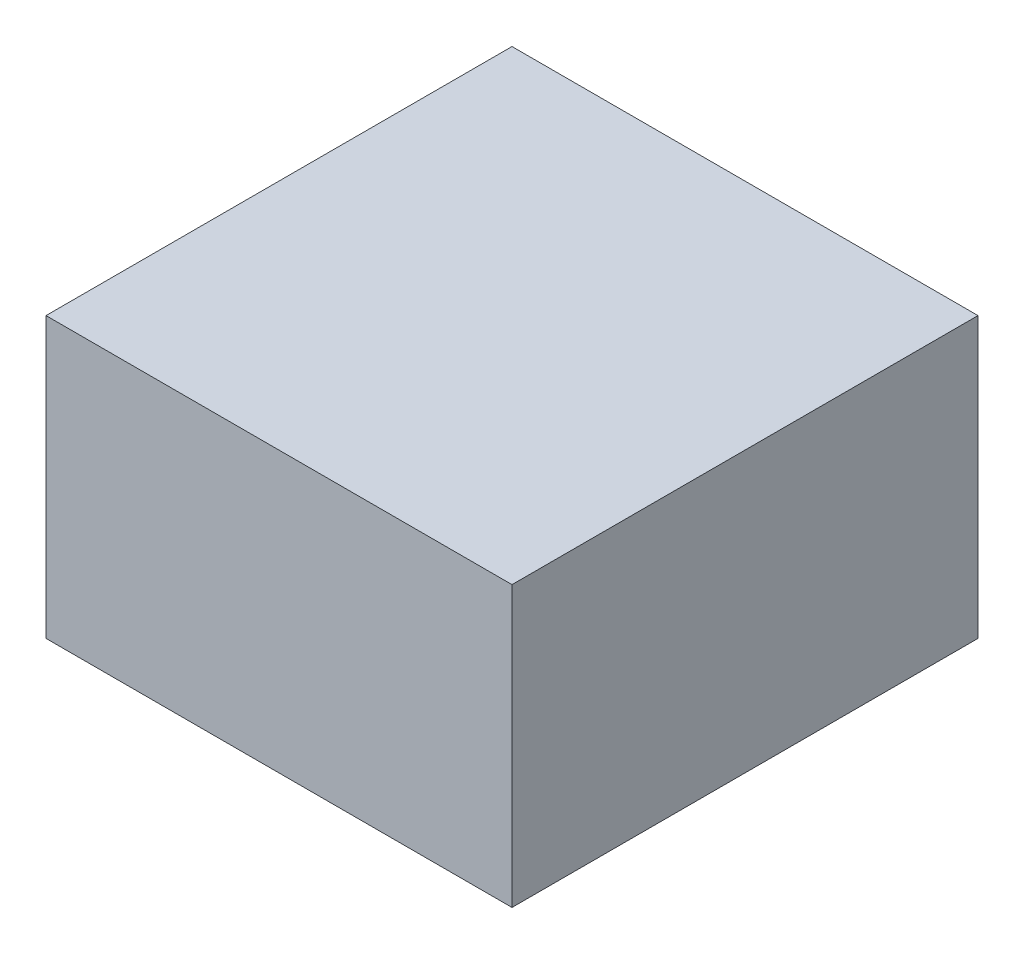
from build123d import *

# Parameters (mm, degrees)
SKETCH1_W           = 63.5
SKETCH1_H           = 63.5
BOSS_EXTRUDE1_DEPTH = 38.1


with BuildPart() as part:
    # Sketch1 → Boss-Extrude1 (new body)
    with BuildSketch(Plane(origin=(0, 0, 0), x_dir=(1, 0, 0), z_dir=(0, 1, 0))):
        Rectangle(SKETCH1_W, SKETCH1_H)
    extrude(amount=BOSS_EXTRUDE1_DEPTH)


solid = part.part
